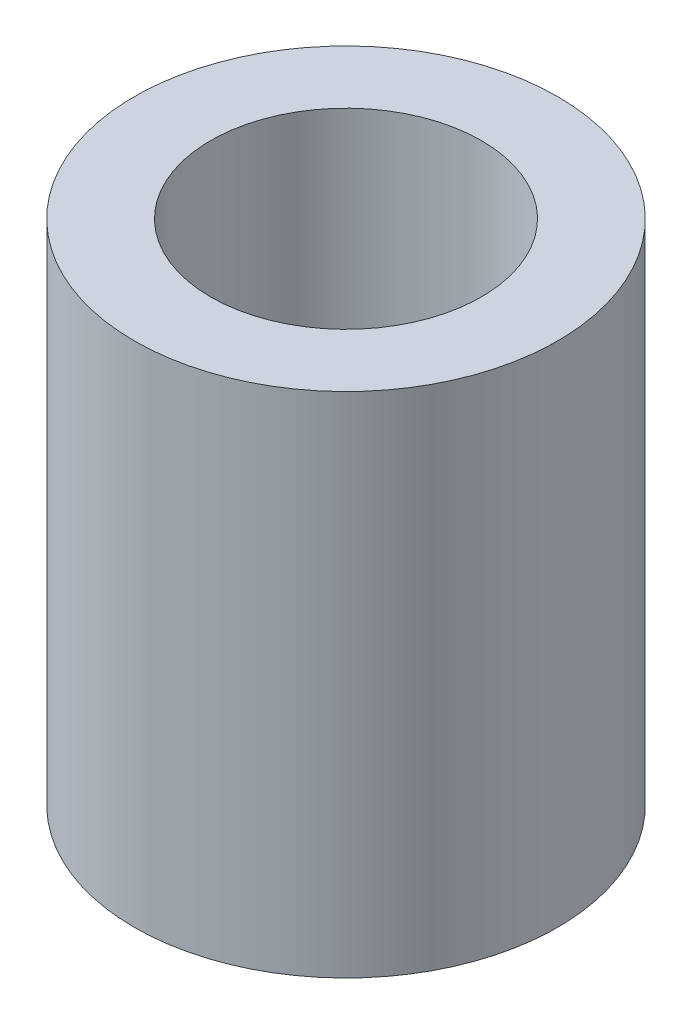
from build123d import *

# Parameters (mm, degrees)
SKETCH1_R           = 2.5
SKETCH1_R_2         = 1.6
BOSS_EXTRUDE1_DEPTH = 6


with BuildPart() as part:
    # Sketch1 → Boss-Extrude1 (new body)
    with BuildSketch(Plane(origin=(0, 0, 0), x_dir=(1, 0, 0), z_dir=(0, 1, 0))):
        Circle(SKETCH1_R)
        Circle(SKETCH1_R_2, mode=Mode.SUBTRACT)
    extrude(amount=BOSS_EXTRUDE1_DEPTH)


solid = part.part
